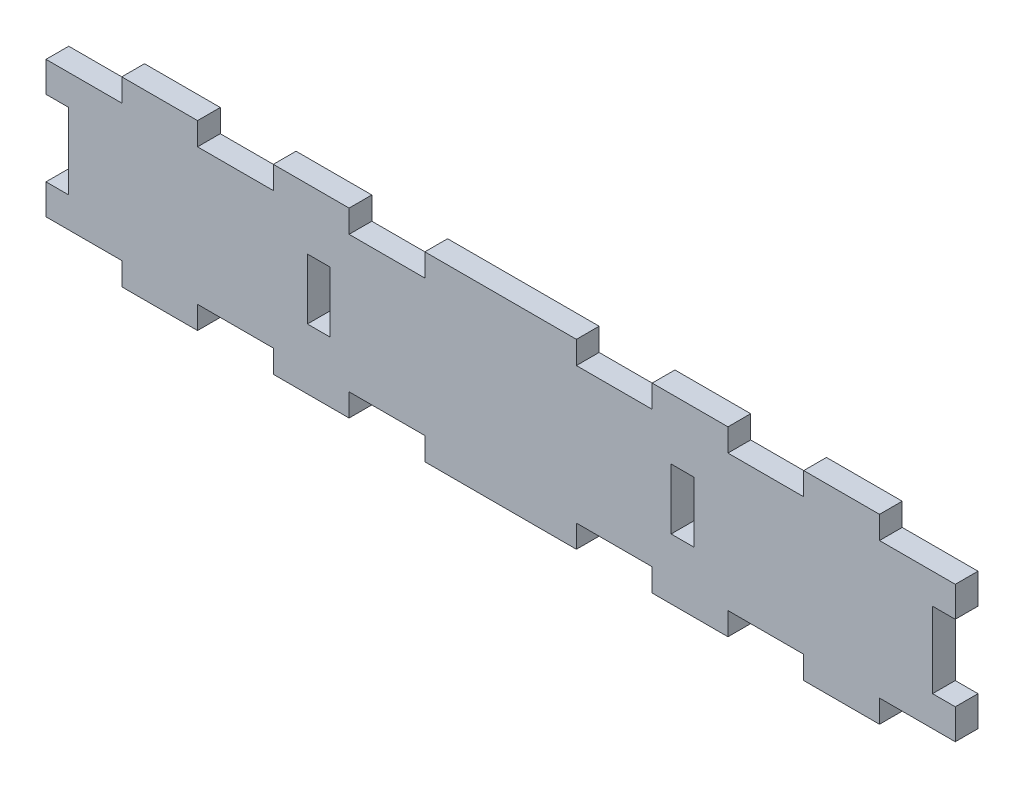
from build123d import *

# Parameters (mm, degrees)
SKETCH1_W               = 120
SKETCH1_H               = 24
BOSS_EXTRUDE1_DEPTH     = 3
SKETCH2_W               = 10
SKETCH2_H               = 3
CUT_EXTRUDE1_DEPTH      = 4
MIRROR3_COPY_1_SKETCH_W = 10
MIRROR3_COPY_1_SKETCH_H = 3
MIRROR3_COPY_1_DEPTH    = 4
SKETCH3_W               = 3
SKETCH3_H               = 8
SKETCH3_H_2             = 10
CUT_EXTRUDE2_DEPTH      = 4


with BuildPart() as part:
    # Sketch1 → Boss-Extrude1 (new body)
    with BuildSketch(Plane.XY):
        Rectangle(SKETCH1_W, SKETCH1_H)
    extrude(amount=BOSS_EXTRUDE1_DEPTH)

    # Sketch2 → Cut-Extrude1 (cut, through all)
    with BuildSketch(Plane.XY.offset(3)):
        with Locations((15, 10.5)):
            Rectangle(SKETCH2_W, SKETCH2_H)
        with Locations((35, 10.5)):
            Rectangle(SKETCH2_W, SKETCH2_H)
        with Locations((55, 10.5)):
            Rectangle(SKETCH2_W, SKETCH2_H)
    cut_extrude1 = extrude(amount=-CUT_EXTRUDE1_DEPTH, mode=Mode.SUBTRACT)

    # Mirror2: Cut-Extrude1 across plane
    add(cut_extrude1.mirror(Plane(origin=(0, 0, 0), x_dir=(0, 0, 1), z_dir=(1, 0, 0))), mode=Mode.SUBTRACT)

    # Mirror3: Cut-Extrude1 across plane
    add(cut_extrude1.mirror(Plane.ZX), mode=Mode.SUBTRACT)

    # Mirror3 copy 1 sketch → Mirror3 copy 1 (cut, through all)
    with BuildSketch(Plane(origin=(0, 0, 3), x_dir=(-1, 0, 0), z_dir=(0, 0, 1))):
        with Locations((15, 10.5)):
            Rectangle(MIRROR3_COPY_1_SKETCH_W, MIRROR3_COPY_1_SKETCH_H)
        with Locations((35, 10.5)):
            Rectangle(MIRROR3_COPY_1_SKETCH_W, MIRROR3_COPY_1_SKETCH_H)
        with Locations((55, 10.5)):
            Rectangle(MIRROR3_COPY_1_SKETCH_W, MIRROR3_COPY_1_SKETCH_H)
    extrude(amount=-MIRROR3_COPY_1_DEPTH, mode=Mode.SUBTRACT)

    # Sketch3 → Cut-Extrude2 (cut, through all)
    with BuildSketch(Plane.XY.offset(3)):
        with Locations((24, 0)):
            Rectangle(SKETCH3_W, SKETCH3_H)
        with Locations((-24, 0)):
            Rectangle(SKETCH3_W, SKETCH3_H)
        with Locations((58.5, 0)):
            Rectangle(SKETCH3_W, SKETCH3_H_2)
        with Locations((-58.5, 0)):
            Rectangle(SKETCH3_W, SKETCH3_H_2)
    extrude(amount=-CUT_EXTRUDE2_DEPTH, mode=Mode.SUBTRACT)


solid = part.part
